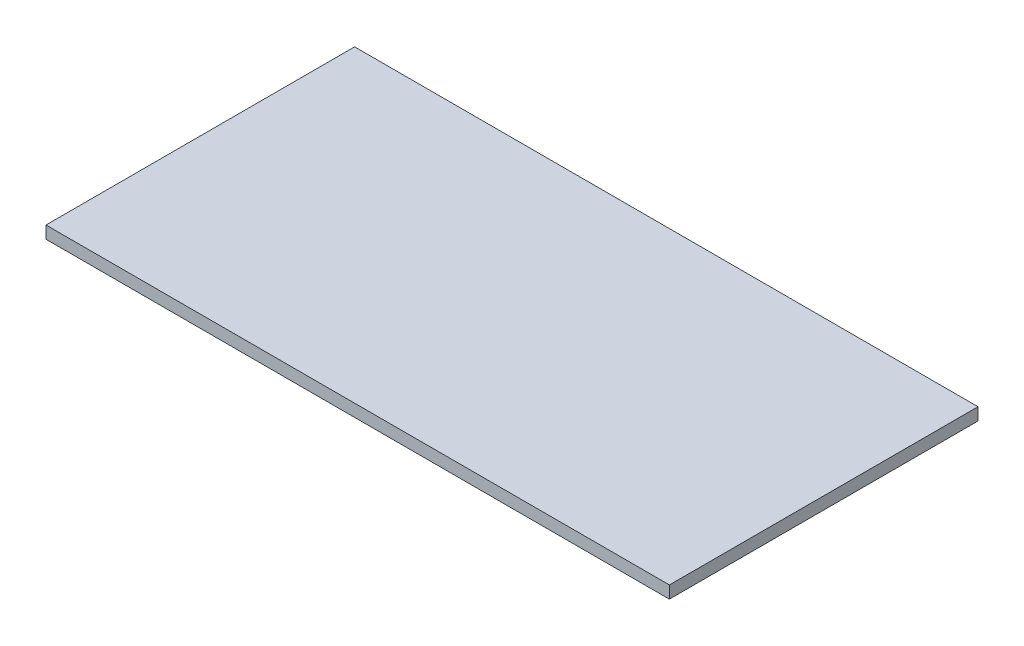
from build123d import *

# Parameters (mm, degrees)
SKETCH1_W           = 641.35
SKETCH1_H           = 317.5
BOSS_EXTRUDE1_DEPTH = 12.7


with BuildPart() as part:
    # Sketch1 → Boss-Extrude1 (new body)
    with BuildSketch(Plane(origin=(0, 0, 0), x_dir=(1, 0, 0), z_dir=(0, 1, 0))):
        Rectangle(SKETCH1_W, SKETCH1_H)
    extrude(amount=BOSS_EXTRUDE1_DEPTH)


solid = part.part
